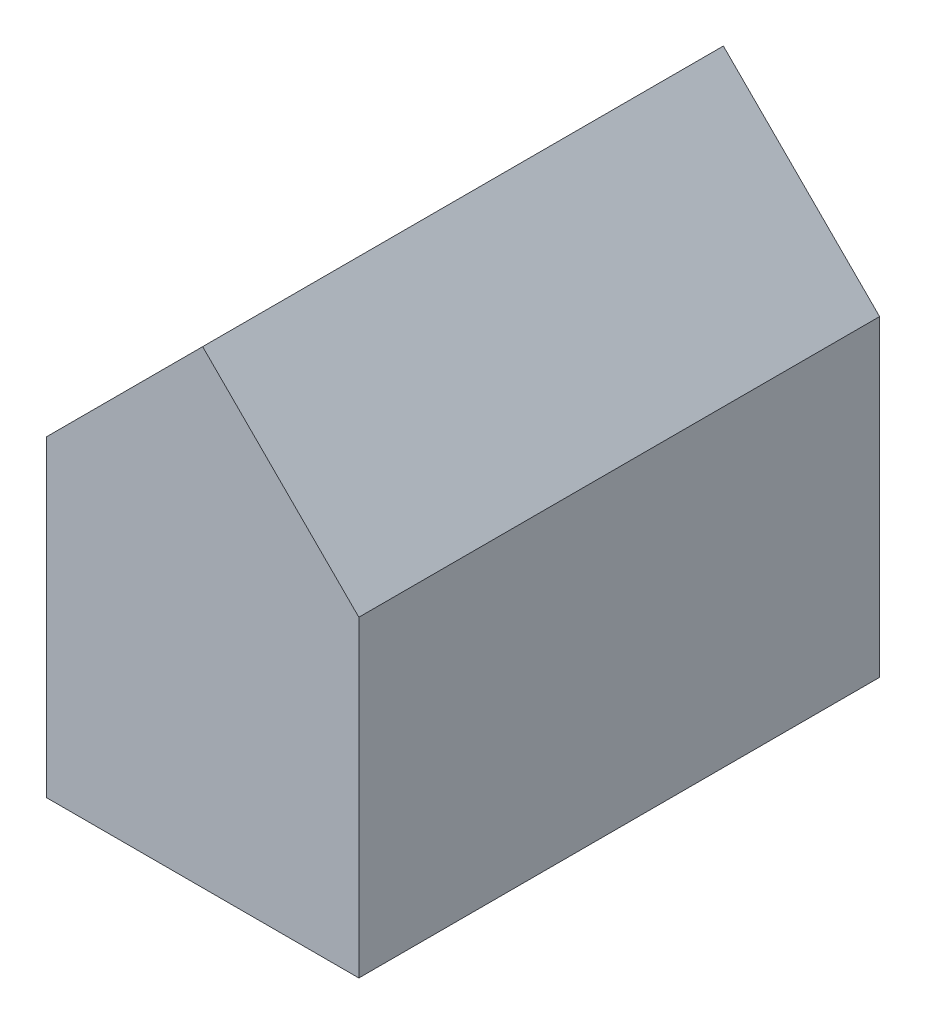
from build123d import *

# Parameters (mm, degrees)
BOSS_EXTRUDE1_DEPTH = 10


with BuildPart() as part:
    # Sketch1 → Boss-Extrude1 (new body)
    with BuildSketch(Plane.XY):
        Polygon((-27.711340206, 16.103092784), (-24.711340206, 19.103092784), (-21.711340206, 16.103092784), (-21.711340206, 10.103092784), (-27.711340206, 10.103092784), align=None)
    extrude(amount=BOSS_EXTRUDE1_DEPTH)


solid = part.part
